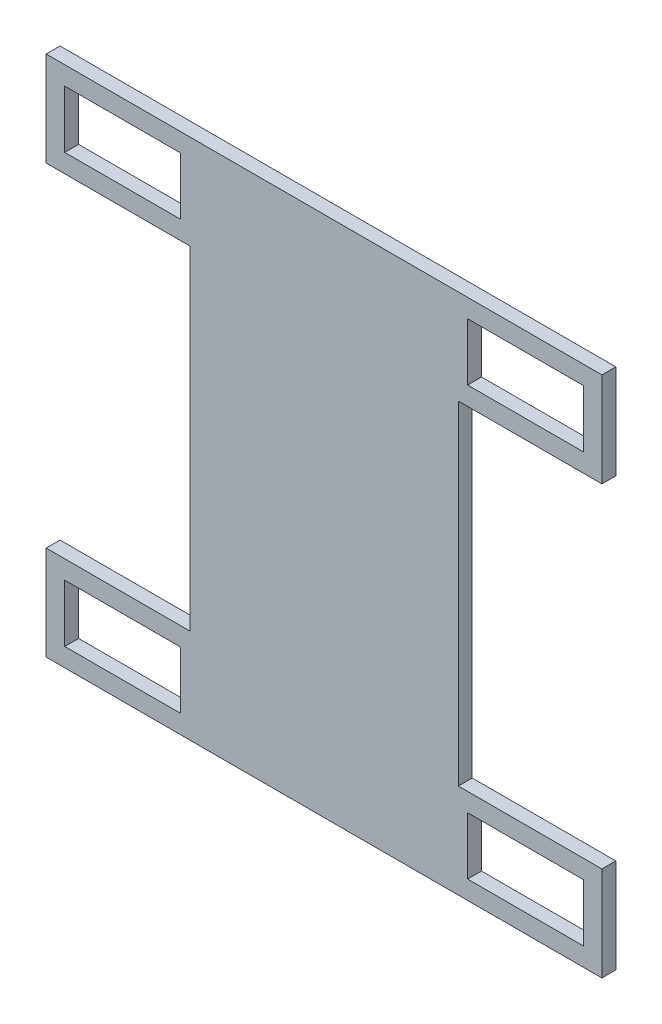
from build123d import *

# Parameters (mm, degrees)
ESBO_O1_W                = 25
ESBO_O1_H                = 12.4
RESSALTO_EXTRUS_O1_DEPTH = 3


with BuildPart() as part:
    # Esboço1 → Ressalto-extrusão1 (new body)
    with BuildSketch(Plane.XY):
        Polygon((-60, 56.4), (60, 56.4), (60, 36), (29, 36), (29, -36), (60, -36), (60, -56.4), (-60, -56.4), (-60, -36), (-29, -36), (-29, 36), (-60, 36), align=None)
        with Locations((43.5, 46.2)):
            Rectangle(ESBO_O1_W, ESBO_O1_H, mode=Mode.SUBTRACT)
        with Locations((43.5, -46.2)):
            Rectangle(ESBO_O1_W, ESBO_O1_H, mode=Mode.SUBTRACT)
        with Locations((-43.5, -46.2)):
            Rectangle(ESBO_O1_W, ESBO_O1_H, mode=Mode.SUBTRACT)
        with Locations((-43.5, 46.2)):
            Rectangle(ESBO_O1_W, ESBO_O1_H, mode=Mode.SUBTRACT)
    extrude(amount=RESSALTO_EXTRUS_O1_DEPTH)


solid = part.part
